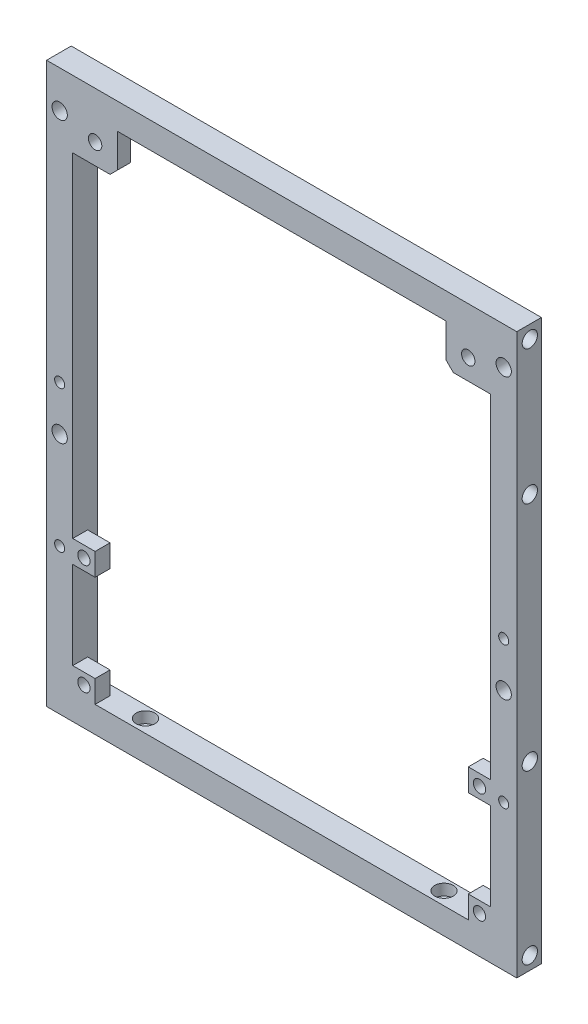
from build123d import *

# Parameters (mm, degrees)
SKETCH1_W                       = 126
SKETCH1_H                       = 150
SKETCH1_W_2                     = 112
SKETCH1_H_2                     = 136
BOSS_EXTRUDE1_DEPTH             = 7
SKETCH2_R                       = 2.05
CUT_EXTRUDE1_DEPTH              = 6
SKETCH3_R                       = 1.35
CUT_EXTRUDE2_DEPTH              = 8
SKETCH4_R                       = 2.5
CUT_EXTRUDE3_DEPTH              = 3
SKETCH5_R                       = 1.35
CUT_EXTRUDE4_DEPTH              = 8
SKETCH6_R                       = 2.5
CUT_EXTRUDE5_DEPTH              = 3
SKETCH7_R                       = 2.05
CUT_EXTRUDE6_DEPTH              = 8
CUT_EXTRUDE7_DEPTH              = 0.2
SKETCH9_W                       = 2.7
SKETCH9_H                       = 2.7
CUT_EXTRUDE8_DEPTH              = 0.2
SKETCH10_W                      = 6
SKETCH10_H                      = 6
BOSS_EXTRUDE2_DEPTH             = 4
SKETCH11_R                      = 1.65
CUT_EXTRUDE9_DEPTH              = 5
CHAMFER1_SIZE                   = 0.4
CHAMFER2_SIZE                   = 0.4
SKIZZE2_W                       = 12
SKIZZE2_H                       = 11
SKIZZE2_R                       = 1.8
AUFSATZ_LINEAR_AUSTRAGEN1_DEPTH = 4
FASE1_SIZE                      = 2
FASE2_SIZE                      = 0.5


with BuildPart() as part:
    # Sketch1 → Boss-Extrude1 (new body)
    with BuildSketch(Plane.XY):
        Rectangle(SKETCH1_W, SKETCH1_H)
        Rectangle(SKETCH1_W_2, SKETCH1_H_2, mode=Mode.SUBTRACT)
    extrude(amount=BOSS_EXTRUDE1_DEPTH)

    # Sketch2 → Cut-Extrude1 (cut)
    with BuildSketch(Plane.ZY.offset(63)):
        with Locations((3.5, -71.5)):
            Circle(SKETCH2_R)
        with Locations((3.5, 71.5)):
            Circle(SKETCH2_R)
        with Locations((3.5, 35.5)):
            Circle(SKETCH2_R)
        with Locations((3.5, -26.5)):
            Circle(SKETCH2_R)
    cut_extrude1 = extrude(amount=-CUT_EXTRUDE1_DEPTH, mode=Mode.SUBTRACT)

    # Mirror1: Cut-Extrude1 across plane
    add(cut_extrude1.mirror(Plane(origin=(0, 0, 0), x_dir=(0, 0, 1), z_dir=(1, 0, 0))), mode=Mode.SUBTRACT)

    # Sketch3 → Cut-Extrude2 (cut, through all)
    with BuildSketch(Plane(origin=(0, -68, 0), x_dir=(1, 0, 0), z_dir=(0, 1, 0))):
        with Locations((40, -3.5)):
            Circle(SKETCH3_R)
        with Locations((-40, -3.5)):
            Circle(SKETCH3_R)
    extrude(amount=-CUT_EXTRUDE2_DEPTH, mode=Mode.SUBTRACT)

    # Sketch4 → Cut-Extrude3 (cut)
    with BuildSketch(Plane(origin=(0, -68, 0), x_dir=(1, 0, 0), z_dir=(0, 1, 0))):
        with Locations((40, -3.5)):
            Circle(SKETCH4_R)
        with Locations((-40, -3.5)):
            Circle(SKETCH4_R)
    extrude(amount=-CUT_EXTRUDE3_DEPTH, mode=Mode.SUBTRACT)

    # Sketch5 → Cut-Extrude4 (cut, through all)
    with BuildSketch(Plane(origin=(0, 0, 0), x_dir=(-1, 0, 0), z_dir=(0, 0, -1))):
        with Locations((-59.5, 2)):
            Circle(SKETCH5_R)
        with Locations((59.5, 2)):
            Circle(SKETCH5_R)
        with Locations((-59.5, -36)):
            Circle(SKETCH5_R)
        with Locations((59.5, -36)):
            Circle(SKETCH5_R)
    extrude(amount=-CUT_EXTRUDE4_DEPTH, mode=Mode.SUBTRACT)

    # Sketch6 → Cut-Extrude5 (cut)
    with BuildSketch(Plane(origin=(0, 0, 0), x_dir=(-1, 0, 0), z_dir=(0, 0, -1))):
        with Locations((-59.5, 2)):
            Circle(SKETCH6_R)
        with Locations((59.5, 2)):
            Circle(SKETCH6_R)
        with Locations((-59.5, -36)):
            Circle(SKETCH6_R)
        with Locations((59.5, -36)):
            Circle(SKETCH6_R)
    extrude(amount=-CUT_EXTRUDE5_DEPTH, mode=Mode.SUBTRACT)

    # Sketch7 → Cut-Extrude6 (cut, through all)
    with BuildSketch(Plane(origin=(0, 0, 0), x_dir=(-1, 0, 0), z_dir=(0, 0, -1))):
        with Locations((-59.5, 65)):
            Circle(SKETCH7_R)
        with Locations((-59.5, -10)):
            Circle(SKETCH7_R)
    cut_extrude6 = extrude(amount=-CUT_EXTRUDE6_DEPTH, mode=Mode.SUBTRACT)

    # Mirror2: Cut-Extrude6 across plane
    add(cut_extrude6.mirror(Plane(origin=(0, 0, 0), x_dir=(0, 0, 1), z_dir=(1, 0, 0))), mode=Mode.SUBTRACT)

    # Sketch8 → Cut-Extrude7 (cut)
    with BuildSketch(Plane(origin=(0, 0, 3), x_dir=(-1, 0, 0), z_dir=(0, 0, -1))):
        with BuildLine():
            Line((-60.85, -0.104162541), (-60.85, 4.104162541))
            ThreePointArc((-60.85, 4.104162541), (-59.5, 4.5), (-58.15, 4.104162541))
            Line((-58.15, 4.104162541), (-58.15, -0.104162541))
            ThreePointArc((-58.15, -0.104162541), (-59.5, -0.5), (-60.85, -0.104162541))
        make_face()
        with BuildLine():
            Line((-60.85, -38.104162541), (-60.85, -33.895837459))
            ThreePointArc((-60.85, -33.895837459), (-59.5, -33.5), (-58.15, -33.895837459))
            Line((-58.15, -33.895837459), (-58.15, -38.104162541))
            ThreePointArc((-58.15, -38.104162541), (-59.5, -38.5), (-60.85, -38.104162541))
        make_face()
    cut_extrude7 = extrude(amount=-CUT_EXTRUDE7_DEPTH, mode=Mode.SUBTRACT)

    # Sketch9 → Cut-Extrude8 (cut)
    with BuildSketch(Plane(origin=(0, 0, 3.2), x_dir=(-1, 0, 0), z_dir=(0, 0, -1))):
        with Locations((-59.5, 2)):
            Rectangle(SKETCH9_W, SKETCH9_H)
        with Locations((-59.5, -36)):
            Rectangle(SKETCH9_W, SKETCH9_H)
    cut_extrude8 = extrude(amount=-CUT_EXTRUDE8_DEPTH, mode=Mode.SUBTRACT)

    # Mirror3: Cut-Extrude7, Cut-Extrude8 across plane
    add(cut_extrude7.mirror(Plane(origin=(0, 0, 0), x_dir=(0, 0, 1), z_dir=(1, 0, 0))), mode=Mode.SUBTRACT)
    add(cut_extrude8.mirror(Plane(origin=(0, 0, 0), x_dir=(0, 0, 1), z_dir=(1, 0, 0))), mode=Mode.SUBTRACT)

    # Sketch10 → Boss-Extrude2 (add)
    with BuildSketch(Plane.XY.offset(7)):
        with Locations((53, -65)):
            Rectangle(SKETCH10_W, SKETCH10_H)
        with Locations((53, -35.5)):
            Rectangle(SKETCH10_W, SKETCH10_H)
    boss_extrude2 = extrude(amount=-BOSS_EXTRUDE2_DEPTH)

    # Sketch11 → Cut-Extrude9 (cut, through all)
    with BuildSketch(Plane(origin=(0, 0, 3), x_dir=(-1, 0, 0), z_dir=(0, 0, -1))):
        with Locations((-53, -35.5)):
            Circle(SKETCH11_R)
        with Locations((-53, -65)):
            Circle(SKETCH11_R)
    cut_extrude9 = extrude(amount=-CUT_EXTRUDE9_DEPTH, mode=Mode.SUBTRACT)

    # Mirror4: Boss-Extrude2, Cut-Extrude9 across plane
    add(boss_extrude2.mirror(Plane(origin=(0, 0, 0), x_dir=(0, 0, 1), z_dir=(1, 0, 0))))
    add(cut_extrude9.mirror(Plane(origin=(0, 0, 0), x_dir=(0, 0, 1), z_dir=(1, 0, 0))), mode=Mode.SUBTRACT)

    # Chamfer1
    chamfer1_edges = [part.edges().sort_by_distance(p)[0] for p in [
        (56, 0, 0),
        (0, 68, 0),
        (-56, 0, 0),
        (0, -68, 0),
    ]]
    chamfer(chamfer1_edges, length=CHAMFER1_SIZE)

    # Chamfer2
    chamfer2_edges = [part.edges().sort_by_distance(p)[0] for p in [
        (0, -75, 0),
        (-63, 0, 0),
        (0, 75, 0),
        (63, 0, 0),
    ]]
    chamfer(chamfer2_edges, length=CHAMFER2_SIZE)

    # Skizze2 → Aufsatz-Linear austragen1 (add)
    with BuildSketch(Plane.XY.offset(7)):
        with Locations((-50, 62.5)):
            Rectangle(SKIZZE2_W, SKIZZE2_H)
        with Locations((-50, 62.5)):
            Circle(SKIZZE2_R, mode=Mode.SUBTRACT)
        with Locations((50, 62.5)):
            Rectangle(SKIZZE2_W, SKIZZE2_H)
        with Locations((50, 62.5)):
            Circle(SKIZZE2_R, mode=Mode.SUBTRACT)
    extrude(amount=-AUFSATZ_LINEAR_AUSTRAGEN1_DEPTH)

    # Fase1
    fase1_edges = [part.edges().sort_by_distance(p)[0] for p in [
        (-44, 57, 5),
        (44, 57, 5),
    ]]
    chamfer(fase1_edges, length=FASE1_SIZE)

    # Fase2
    fase2_edges = [part.edges().sort_by_distance(p)[0] for p in [
        (-51, 57, 3),
        (44, 63.5, 3),
        (-44, 63.5, 3),
        (-45, 58, 3),
        (51, 57, 3),
        (45, 58, 3),
    ]]
    chamfer(fase2_edges, length=FASE2_SIZE)


solid = part.part
